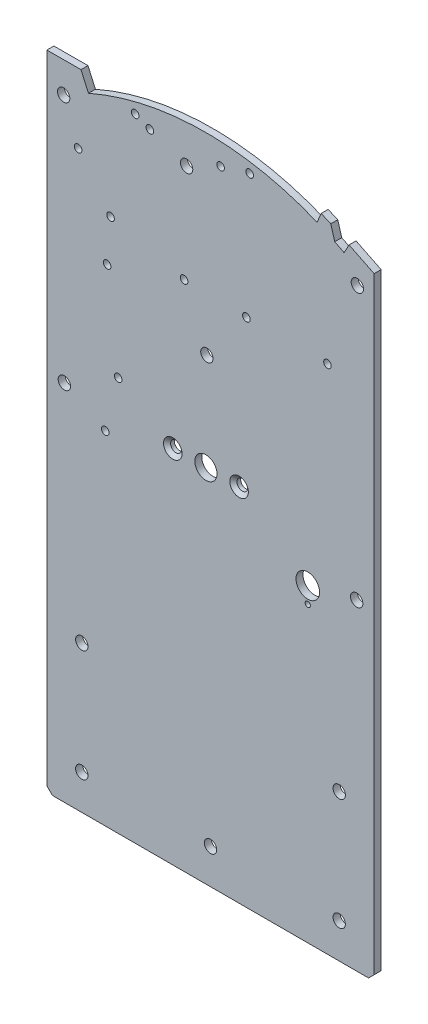
from build123d import *

# Parameters (mm, degrees)
BOSS_EXTRUDE1_DEPTH                       = 3.175
SKETCH2_R                                 = 5.0419
CUT_EXTRUDE1_DEPTH                        = 4.175
F_4_CLEARANCE_HOLE1_D                     = 3.4544
F_10_CLEARANCE_HOLE1_D                    = 5.6134
F_4_CLEARANCE_HOLE2_D                     = 3.4544
F_27_64_0_42188_DIAMETER_HOLE1_D          = 10.715752
F_3_32_0_09375_DIAMETER_HOLE1_D           = 2.38125
F_10_CLEARANCE_HOLE2_D                    = 5.6134
SKETCH15_W                                = 148.719955274
SKETCH15_H                                = 114.3
BOSS_EXTRUDE2_DEPTH                       = 3.175
CHAMFER1_SIZE                             = 2.54
F_10_CLEARANCE_HOLE3_D                    = 5.6134
CSK_FOR_8_FLAT_HEAD_MACHINE_SCREW_2_COUNT = 2
CSK_FOR_8_FLAT_HEAD_MACHINE_SCREW_2_PITCH = 30.13075


with BuildPart() as part:
    # Sketch1 → Boss-Extrude1 (new body)
    with BuildSketch(Plane.XY):
        with BuildLine():
            Line((-37.014245685, -65.193042462), (-37.014245685, -242.993042462))
            Line((-37.014245685, -242.993042462), (111.705709589, -242.993042462))
            Line((111.705709589, -242.993042462), (111.705709589, -78.837199032))
            Line((111.705709589, -78.837199032), (100.315919098, -73.219132409))
            Line((100.315919098, -73.219132409), (98.04889923, -77.407452736))
            ThreePointArc((98.04889923, -77.407452736), (95.944511883, -76.292837527), (93.820355363, -75.216374688))
            Line((93.820355363, -75.216374688), (91.991959695, -69.073183497))
            Line((91.991959695, -69.073183497), (87.625459733, -67.171845985))
            Line((87.625459733, -67.171845985), (85.800454124, -71.570795948))
            ThreePointArc((85.800454124, -71.570795948), (33.712742218, -61.505341345), (-18.130011823, -72.76464689))
            Line((-18.130011823, -72.76464689), (-20.055584156, -68.408779876))
            Line((-20.055584156, -68.408779876), (-21.49685031, -65.148469374))
            Line((-21.49685031, -65.148469374), (-28.430836618, -65.168386968))
            Line((-28.430836618, -65.168386968), (-37.014245685, -65.193042462))
        make_face()
    extrude(amount=-BOSS_EXTRUDE1_DEPTH)

    # Sketch2 → Cut-Extrude1 (cut, through all)
    with BuildSketch(Plane.XY):
        with Locations((35.268404938, -193.371995598)):
            Circle(SKETCH2_R)
    extrude(amount=-CUT_EXTRUDE1_DEPTH, mode=Mode.SUBTRACT)

    # #4 Clearance Hole1 (through all)
    with Locations(Plane.XY):
        with Locations((41.939844363, -71.488811907), (9.789450293, -73.011273216), (90.488583573, -124.967078721), (53.658735514, -125.072870965), (25.338848707, -124.341705755), (-9.634401538, -135.888162669), (55.145248163, -67.700310852), (3.101953943, -70.270684884)):
            Hole(F_4_CLEARANCE_HOLE1_D / 2)

    # #10 Clearance Hole1 (through all)
    with Locations(Plane.XY):
        with Locations((-29.394245685, -79.071995598), (104.085709589, -87.326995598), (35.695953558, -148.921995598), (26.485754315, -79.071995598)):
            Hole(F_10_CLEARANCE_HOLE1_D / 2)

    # #4 Clearance Hole2 (through all)
    with Locations(Plane.XY):
        with Locations((-8.073739309, -116.319383279), (-22.812224861, -96.782058908), (-10.478566815, -201.738004366), (-4.603970045, -177.980497914)):
            Hole(F_4_CLEARANCE_HOLE2_D / 2)

    # 27/64 (0.42188) Diameter Hole1 (through all)
    with Locations(Plane.XY):
        with Locations((81.551198953, -216.670082089)):
            Hole(F_27_64_0_42188_DIAMETER_HOLE1_D / 2)

    # 3/32 (0.09375) Diameter Hole1 (through all)
    with Locations(Plane.XY):
        with Locations((81.551198953, -224.036082089)):
            Hole(F_3_32_0_09375_DIAMETER_HOLE1_D / 2)

    # #10 Clearance Hole2 (through all)
    with Locations(Plane.XY):
        with Locations((-29.076745685, -192.193042462), (103.768209589, -211.243042462)):
            Hole(F_10_CLEARANCE_HOLE2_D / 2)

    # Sketch15 → Boss-Extrude2 (add, through all)
    with BuildSketch(Plane.XY):
        with Locations((37.345731952, -300.143042462)):
            Rectangle(SKETCH15_W, SKETCH15_H)
    extrude(amount=-BOSS_EXTRUDE2_DEPTH)

    # Chamfer1
    chamfer1_edges = [part.edges().sort_by_distance(p)[0] for p in [
        (-37.014245685, -357.293042462, -1.5875),
        (111.705709589, -357.293042462, -1.5875),
    ]]
    chamfer(chamfer1_edges, length=CHAMFER1_SIZE)

    # #10 Clearance Hole3 (through all)
    with Locations(Plane.XY):
        with Locations((95.830709589, -341.418042462), (37.345731952, -341.418042462), (-21.139245685, -341.418042462), (95.830709589, -290.618042462), (-21.139245685, -290.618042462)):
            Hole(F_10_CLEARANCE_HOLE3_D / 2)

    # Sketch19 → CSK for #8 Flat Head Machine Screw (100)2 (revolve, cut)
    with BuildSketch(Plane(origin=(20.203029938, -193.371995598, 0), x_dir=(0, -1, 0), z_dir=(1, 0, 0))):
        Polygon((0, 0), (0, 3.175), (2.45745, 3.175), (2.45745, 1.475934296), (4.2164, 0), align=None)
    csk_for_8_flat_head_machine_screw_100 = revolve(axis=Axis((20.203029938, -193.371995598, 6.35), (0, 0, -1)), mode=Mode.SUBTRACT)

    # CSK for _8 Flat Head Machine Screw _ 2: CSK for #8 Flat Head Machine Screw (100)2 ×2
    with Locations(*[(i * CSK_FOR_8_FLAT_HEAD_MACHINE_SCREW_2_PITCH, 0, 0) for i in range(1, CSK_FOR_8_FLAT_HEAD_MACHINE_SCREW_2_COUNT)]):
        add(csk_for_8_flat_head_machine_screw_100, mode=Mode.SUBTRACT)


solid = part.part
